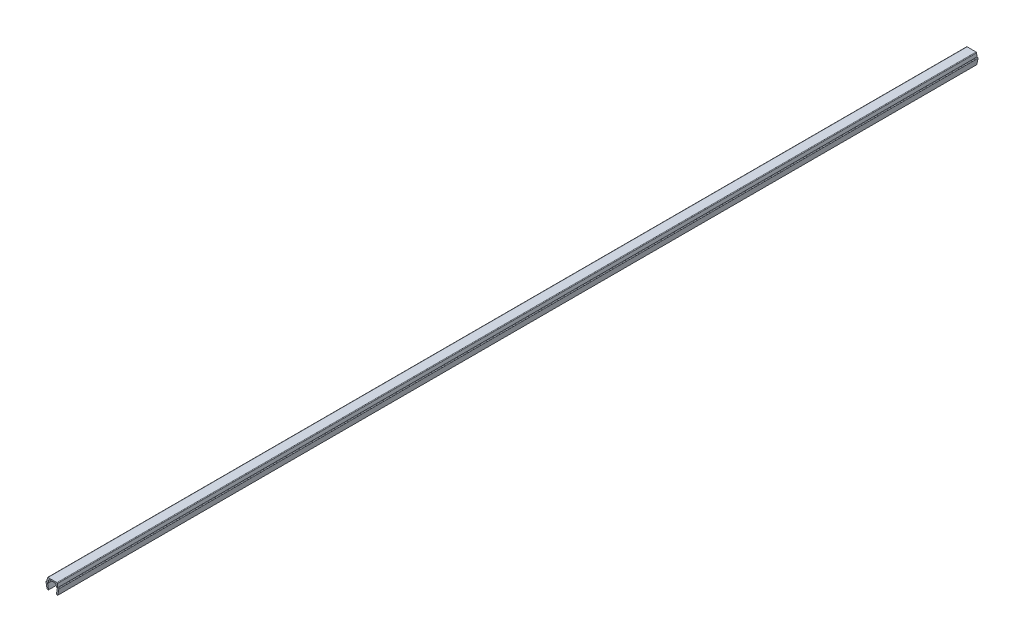
from build123d import *

# Parameters (mm, degrees)
BOSS_EXTRUDE1_DEPTH = 257.5


with BuildPart() as part:
    # Sketch1 → Boss-Extrude1 (new body, symmetric)
    with BuildSketch(Plane.XY):
        with BuildLine():
            Line((-3.6, 3.35), (-3, 0))
            Line((-3, 0), (-2.2, 0))
            Line((-2.2, 0), (-2.735217071, 2.988295315))
            ThreePointArc((-2.735217071, 2.988295315), (-2.659117427, 3.274614514), (-2.390699246, 3.4))
            Line((-2.390699246, 3.4), (-2.2, 3.4))
            Line((-2.2, 3.4), (-2.070472639, 4.88050451))
            ThreePointArc((-2.070472639, 4.88050451), (-1.958261067, 5.108047068), (-1.721804495, 5.2))
            Line((-1.721804495, 5.2), (1.721804495, 5.2))
            ThreePointArc((1.721804495, 5.2), (1.958261067, 5.108047068), (2.070472639, 4.88050451))
            Line((2.070472639, 4.88050451), (2.2, 3.4))
            Line((2.2, 3.4), (2.390699246, 3.4))
            ThreePointArc((2.390699246, 3.4), (2.659117427, 3.274614514), (2.735217071, 2.988295315))
            Line((2.735217071, 2.988295315), (2.2, 0))
            Line((2.2, 0), (3, 0))
            Line((3, 0), (3.6, 3.35))
            ThreePointArc((3.6, 3.35), (3.497487373, 3.597487373), (3.25, 3.7))
            Line((3.25, 3.7), (3, 3.7))
            Line((3, 3.7), (2.835477174, 5.58050451))
            ThreePointArc((2.835477174, 5.58050451), (2.723265602, 5.808047068), (2.486809029, 5.9))
            Line((2.486809029, 5.9), (-2.486809029, 5.9))
            ThreePointArc((-2.486809029, 5.9), (-2.723265602, 5.808047068), (-2.835477174, 5.58050451))
            Line((-2.835477174, 5.58050451), (-3, 3.7))
            Line((-3, 3.7), (-3.25, 3.7))
            ThreePointArc((-3.25, 3.7), (-3.497487373, 3.597487373), (-3.6, 3.35))
        make_face()
    extrude(amount=BOSS_EXTRUDE1_DEPTH, both=True)


solid = part.part
